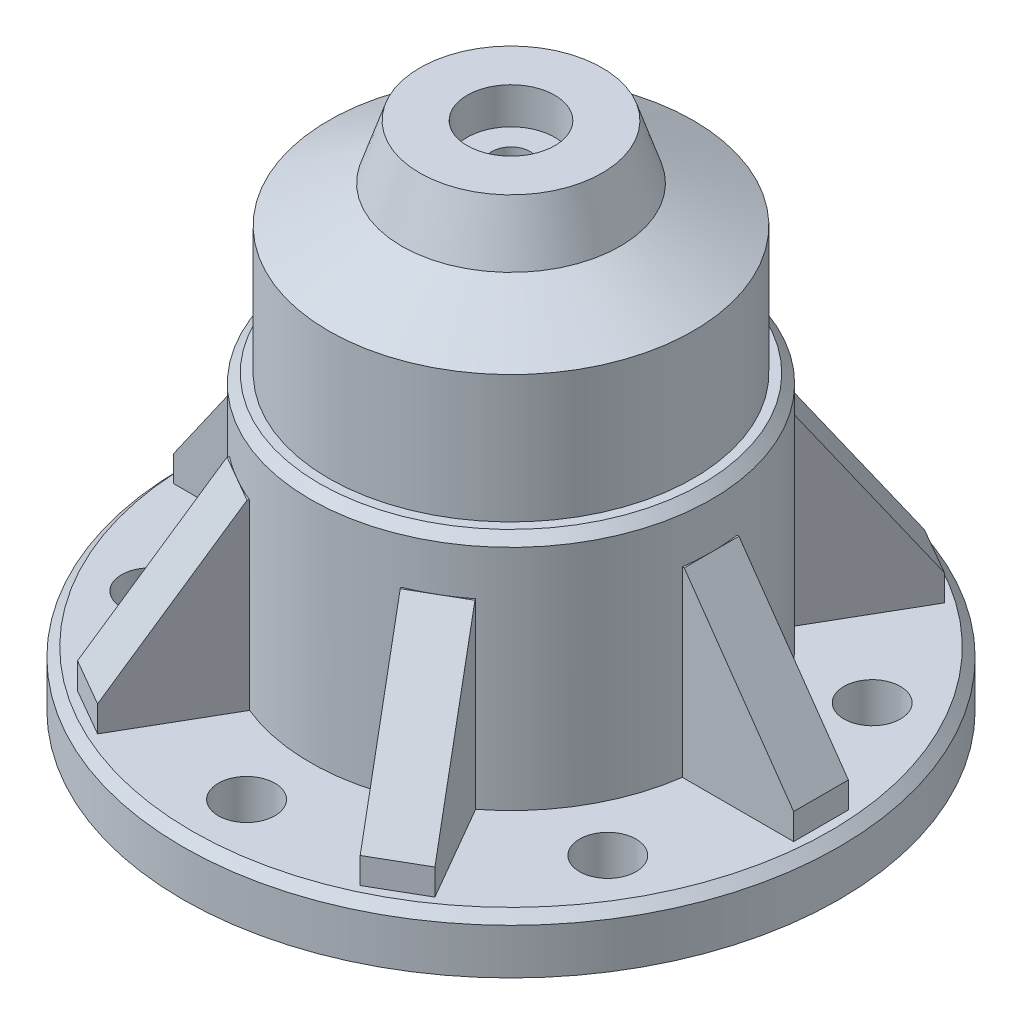
from build123d import *

# Parameters (mm, degrees)
SKETCH1_R                = 18
SKETCH1_R_2              = 8
BOSS_EXTRUDE1_DEPTH      = 3
SKETCH2_R                = 11
SKETCH2_R_2              = 8
BOSS_EXTRUDE2_DEPTH      = 22
M_0_295_DIAMETER_HOLE1_D = 3.099999896
BOSS_EXTRUDE3_DEPTH      = 1.5
CIRPATTERN1_COUNT        = 6
CHAMFER2_SIZE            = 0.5
SKETCH6_R                = 11
BOSS_EXTRUDE4_DEPTH      = 3
SKETCH8_R                = 8
BOSS_EXTRUDE5_DEPTH      = 2
CHAMFER3_SIZE            = 6
SKETCH7_R                = 2.4
CUT_EXTRUDE1_DEPTH       = 2
CUT_EXTRUDE2_REACH       = 28
SKETCH9_R                = 1.05
SKETCH10_R               = 11
SKETCH10_R_2             = 10
CUT_EXTRUDE3_DEPTH       = 12
CHAMFER4_SIZE            = 0.5
CHAMFER5_SIZE            = 2
CHAMFER5_SIZE2           = 3.464101615


with BuildPart() as part:
    # Sketch1 → Boss-Extrude1 (new body)
    with BuildSketch(Plane(origin=(0, 0, 0), x_dir=(1, 0, 0), z_dir=(0, 1, 0))):
        Circle(SKETCH1_R)
        Circle(SKETCH1_R_2, mode=Mode.SUBTRACT)
    extrude(amount=BOSS_EXTRUDE1_DEPTH)

    # Sketch2 → Boss-Extrude2 (add)
    with BuildSketch(Plane(origin=(0, 3, 0), x_dir=(1, 0, 0), z_dir=(0, 1, 0))):
        Circle(SKETCH2_R)
        Circle(SKETCH2_R_2, mode=Mode.SUBTRACT)
    extrude(amount=BOSS_EXTRUDE2_DEPTH)

    # M (0.295) Diameter Hole1 (through all)
    with Locations(Plane(origin=(0, 3, 14.5), x_dir=(0, 0, 1), z_dir=(0, 1, 0))):
        with Locations((0, 0), (-7.25, -12.557368355), (-7.25, 12.557368355), (-21.75, 12.557368355), (-29, 0), (-21.75, -12.557368355)):
            Hole(M_0_295_DIAMETER_HOLE1_D / 2)

    # Sketch5 → Boss-Extrude3 (add, symmetric)
    with BuildSketch(Plane.XY):
        Polygon((11, 13), (17, 4.428571429), (17, 3), (17, 2.5), (10.5, 2.5), (10.5, 13), align=None)
    boss_extrude3 = extrude(amount=BOSS_EXTRUDE3_DEPTH, both=True)

    # CirPattern1: Boss-Extrude3 ×6 about axis
    cirpattern1_axis = Axis((0, 0, 0), (0, 1, 0))
    for i in range(1, CIRPATTERN1_COUNT):
        add(boss_extrude3.rotate(cirpattern1_axis, i * 360 / CIRPATTERN1_COUNT))

    # Chamfer2
    chamfer2_edges = [part.edges().sort_by_distance(p)[0] for p in [
        (-18, 3, 0),
    ]]
    chamfer(chamfer2_edges, length=CHAMFER2_SIZE)

    # Sketch6 → Boss-Extrude4 (add)
    with BuildSketch(Plane(origin=(0, 25, 0), x_dir=(1, 0, 0), z_dir=(0, 1, 0))):
        Circle(SKETCH6_R)
    extrude(amount=BOSS_EXTRUDE4_DEPTH)

    # Sketch8 → Boss-Extrude5 (add)
    with BuildSketch(Plane.XZ.offset(-25)):
        Circle(SKETCH8_R)
    extrude(amount=BOSS_EXTRUDE5_DEPTH)

    # Chamfer3
    chamfer3_edges = [part.edges().sort_by_distance(p)[0] for p in [
        (-11, 28, 0),
    ]]
    chamfer(chamfer3_edges, length=CHAMFER3_SIZE)

    # Sketch7 → Cut-Extrude1 (cut)
    with BuildSketch(Plane(origin=(0, 28, 0), x_dir=(1, 0, 0), z_dir=(0, 1, 0))):
        Circle(SKETCH7_R)
    extrude(amount=-CUT_EXTRUDE1_DEPTH, mode=Mode.SUBTRACT)

    # Sketch9 → Cut-Extrude2 (cut, up to next)
    with BuildSketch(Plane(origin=(0, 26, 0), x_dir=(1, 0, 0), z_dir=(0, 1, 0)), mode=Mode.PRIVATE) as cut_extrude2_sk1:
        Circle(SKETCH9_R)
    cut_extrude2_tool1 = extrude(cut_extrude2_sk1.sketch, amount=-CUT_EXTRUDE2_REACH, mode=Mode.PRIVATE) & part.part
    add(cut_extrude2_tool1.solids().sort_by_distance((0, 26, 0))[0], mode=Mode.SUBTRACT)

    # Sketch10 → Cut-Extrude3 (cut)
    with BuildSketch(Plane(origin=(0, 28, 0), x_dir=(1, 0, 0), z_dir=(0, 1, 0))):
        Circle(SKETCH10_R)
        Circle(SKETCH10_R_2, mode=Mode.SUBTRACT)
    extrude(amount=-CUT_EXTRUDE3_DEPTH, mode=Mode.SUBTRACT)

    # Chamfer4
    chamfer4_edges = [part.edges().sort_by_distance(p)[0] for p in [
        (-11, 16, 0),
    ]]
    chamfer(chamfer4_edges, length=CHAMFER4_SIZE)

    # Sketch11 → Cut-Revolve1 (revolve, cut)
    with BuildSketch(Plane.XY):
        Polygon((-5, 28), (-5, 29.257596247), (-10, 29.257596247), (-10, 23), (-5.989740888, 25.017543101), align=None)
    revolve(axis=Axis((0, 18, 0), (0, -1, 0)), mode=Mode.SUBTRACT)

    # Chamfer5
    chamfer5_edges = [part.edges().sort_by_distance(p)[0] for p in [
        (-8, 23, 0),
    ]]
    chamfer5_side = [part.faces().sort_by_distance(p)[0] for p in [
        (-8, 11.5, 0),
    ]]
    chamfer(chamfer5_edges, length=CHAMFER5_SIZE, length2=CHAMFER5_SIZE2, reference=chamfer5_side[0])


solid = part.part
